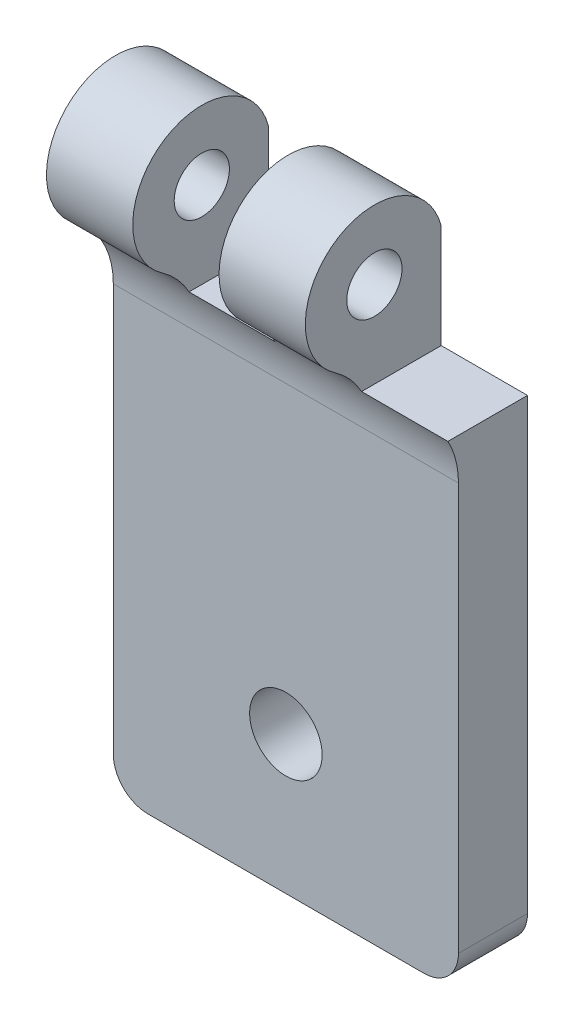
from build123d import *

# Parameters (mm, degrees)
SKETCH1_W           = 20
SKETCH1_H           = 34
BOSS_EXTRUDE1_DEPTH = 4
BOSS_EXTRUDE2_DEPTH = 20
FILLET1_R           = 5
SKETCH3_R           = 1.6
CUT_EXTRUDE1_DEPTH  = 21
SKETCH4_R           = 2.1
CUT_EXTRUDE2_DEPTH  = 5
FILLET2_R           = 2
SKETCH5_W           = 5
SKETCH5_H           = 12
CUT_EXTRUDE3_DEPTH  = 8.872457626


with BuildPart() as part:
    # Sketch1 → Boss-Extrude1 (new body)
    with BuildSketch(Plane.XY):
        with Locations((-10, 17)):
            Rectangle(SKETCH1_W, SKETCH1_H)
    extrude(amount=BOSS_EXTRUDE1_DEPTH)

    # Sketch2 → Boss-Extrude2 (add)
    with BuildSketch(Plane(origin=(0, 0, 0), x_dir=(0, 0, -1), z_dir=(1, 0, 0))):
        with BuildLine():
            Line((-4, 29), (-4, 34))
            Line((-4, 34), (0, 34))
            ThreePointArc((0, 34), (-6.995932864, 35.496746291), (-4, 29))
        make_face()
    extrude(amount=-BOSS_EXTRUDE2_DEPTH)

    # Fillet1
    fillet1_edges = [part.edges().sort_by_distance(p)[0] for p in [
        (-10, 29, 4),
    ]]
    fillet(fillet1_edges, radius=FILLET1_R)

    # Sketch3 → Cut-Extrude1 (cut, through all)
    with BuildSketch(Plane(origin=(0, 0, 0), x_dir=(0, 0, -1), z_dir=(1, 0, 0))):
        with Locations((-3.872457626, 32.997966101)):
            Circle(SKETCH3_R)
    extrude(amount=-CUT_EXTRUDE1_DEPTH, mode=Mode.SUBTRACT)

    # Sketch4 → Cut-Extrude2 (cut, through all)
    with BuildSketch(Plane.XY.offset(4)):
        with Locations((-10, 8)):
            Circle(SKETCH4_R)
    extrude(amount=-CUT_EXTRUDE2_DEPTH, mode=Mode.SUBTRACT)

    # Fillet2
    fillet2_edges = [part.edges().sort_by_distance(p)[0] for p in [
        (0, 0, 2),
        (-20, 0, 2),
    ]]
    fillet(fillet2_edges, radius=FILLET2_R)

    # Sketch5 → Cut-Extrude3 (cut, through all)
    with BuildSketch(Plane(origin=(0, 0, 0), x_dir=(-1, 0, 0), z_dir=(0, 0, -1))):
        with Locations((2.5, 34)):
            Rectangle(SKETCH5_W, SKETCH5_H)
        with Locations((12.5, 34)):
            Rectangle(SKETCH5_W, SKETCH5_H)
    extrude(amount=-CUT_EXTRUDE3_DEPTH, mode=Mode.SUBTRACT)


solid = part.part
